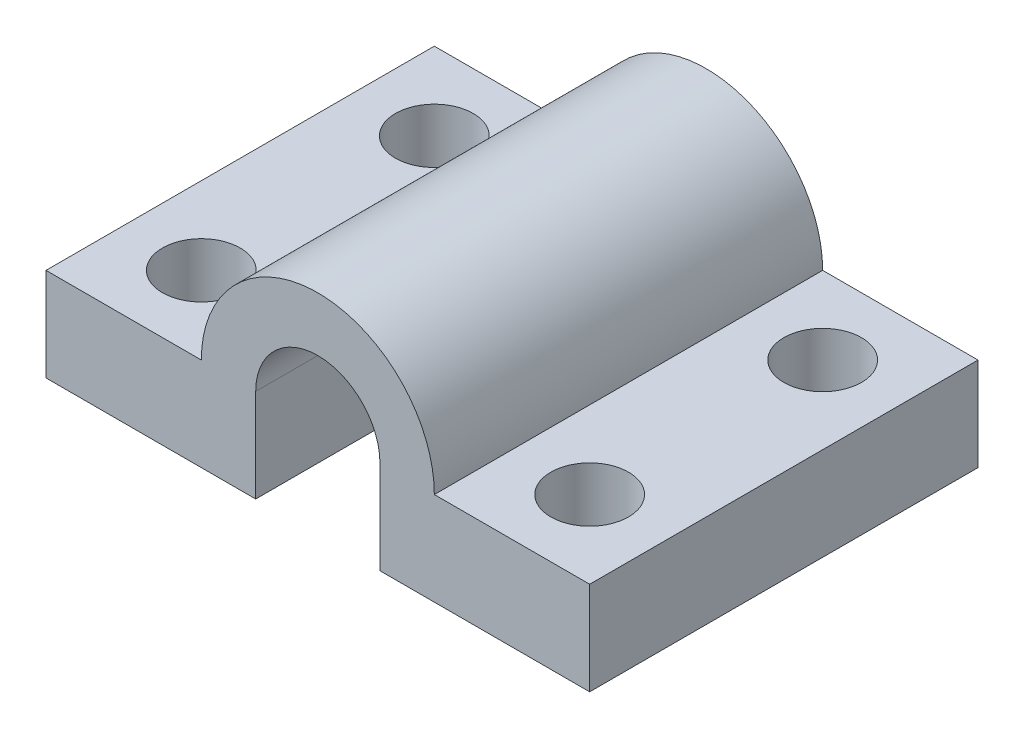
from build123d import *

# Parameters (mm, degrees)
SKETCH1_W           = 35
SKETCH1_H           = 25
BOSS_EXTRUDE1_DEPTH = 6
SKETCH2_R           = 2.5
CUT_EXTRUDE1_DEPTH  = 6
SKETCH3_W           = 7.5
SKETCH3_H           = 25
REVOLVE1_ANGLE      = 180
CUT_EXTRUDE2_DEPTH  = 36


with BuildPart() as part:
    # Sketch1 → Boss-Extrude1 (new body)
    with BuildSketch(Plane(origin=(0, 0, 0), x_dir=(1, 0, 0), z_dir=(0, 1, 0))):
        with Locations((5.286458333, -4.114583333)):
            Rectangle(SKETCH1_W, SKETCH1_H)
    extrude(amount=BOSS_EXTRUDE1_DEPTH)

    # Sketch2 → Cut-Extrude1 (cut)
    with BuildSketch(Plane(origin=(0, 6, 0), x_dir=(1, 0, 0), z_dir=(0, 1, 0))):
        with Locations((-7.213541667, -11.614583333)):
            Circle(SKETCH2_R)
        with Locations((17.786458333, 3.385416667)):
            Circle(SKETCH2_R)
        with Locations((17.786458333, -11.614583333)):
            Circle(SKETCH2_R)
        with Locations((-7.213541667, 3.385416667)):
            Circle(SKETCH2_R)
    extrude(amount=-CUT_EXTRUDE1_DEPTH, mode=Mode.SUBTRACT)

    # Sketch3 → Revolve1 (revolve)
    with BuildSketch(Plane(origin=(0, 6, 0), x_dir=(1, 0, 0), z_dir=(0, 1, 0))):
        with Locations((9.036458333, -4.114583333)):
            Rectangle(SKETCH3_W, SKETCH3_H)
    revolve(axis=Axis((5.286458333, 6, -8.385416667), (0, 0, 1)), revolution_arc=REVOLVE1_ANGLE)

    # Sketch4 → Cut-Extrude2 (cut)
    with BuildSketch(Plane.XY.offset(16.614583333)):
        with BuildLine():
            ThreePointArc((9.286458333, 6), (5.286458333, 10), (1.286458333, 6))
            Line((1.286458333, 6), (9.286458333, 6))
        make_face()
        with BuildLine():
            Line((9.286458333, 6), (1.286458333, 6))
            ThreePointArc((1.286458333, 6), (5.286458333, 2), (9.286458333, 6))
        make_face()
        with BuildLine():
            ThreePointArc((9.286458333, 6), (5.286458333, 2), (1.286458333, 6))
            Line((1.286458333, 6), (1.286458333, 0))
            Line((1.286458333, 0), (9.286458333, 0))
            Line((9.286458333, 0), (9.286458333, 6))
        make_face()
    extrude(amount=-CUT_EXTRUDE2_DEPTH, mode=Mode.SUBTRACT)


solid = part.part
